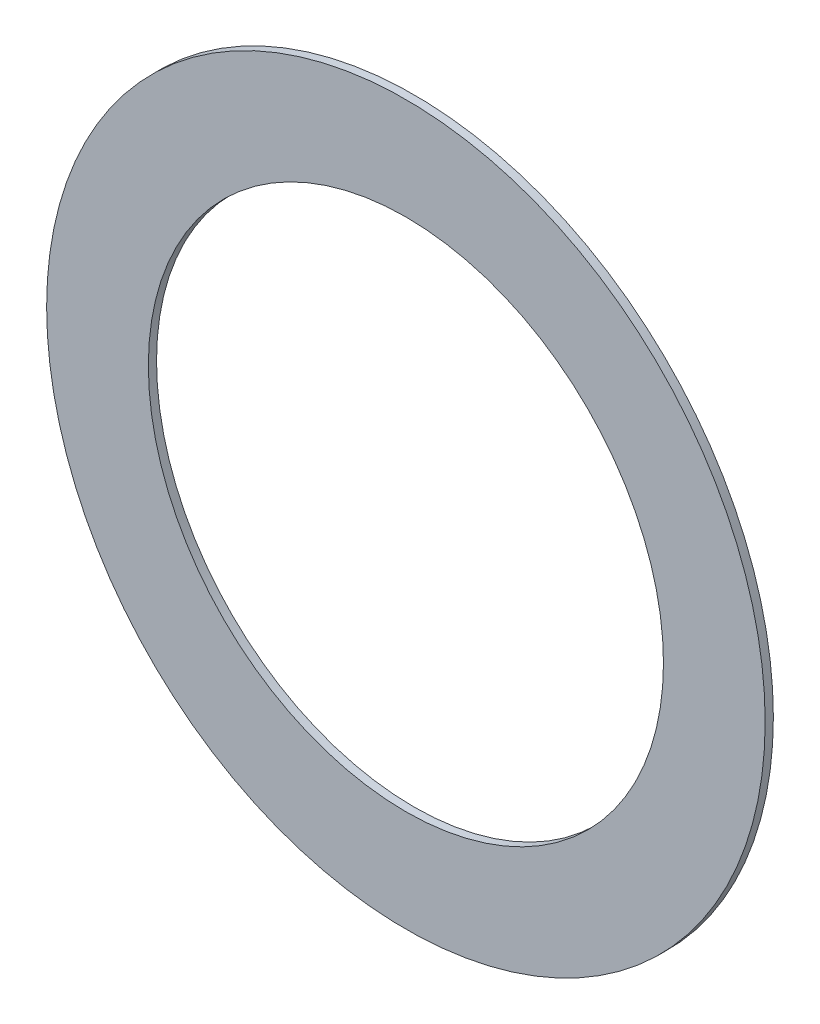
from build123d import *

# Parameters (mm, degrees)
SKETCH1_R           = 5.5626
SKETCH1_R_2         = 3.9878
BOSS_EXTRUDE1_DEPTH = 0.127


with BuildPart() as part:
    # Sketch1 → Boss-Extrude1 (new body)
    with BuildSketch(Plane.XY):
        Circle(SKETCH1_R)
        Circle(SKETCH1_R_2, mode=Mode.SUBTRACT)
    extrude(amount=BOSS_EXTRUDE1_DEPTH)


solid = part.part
